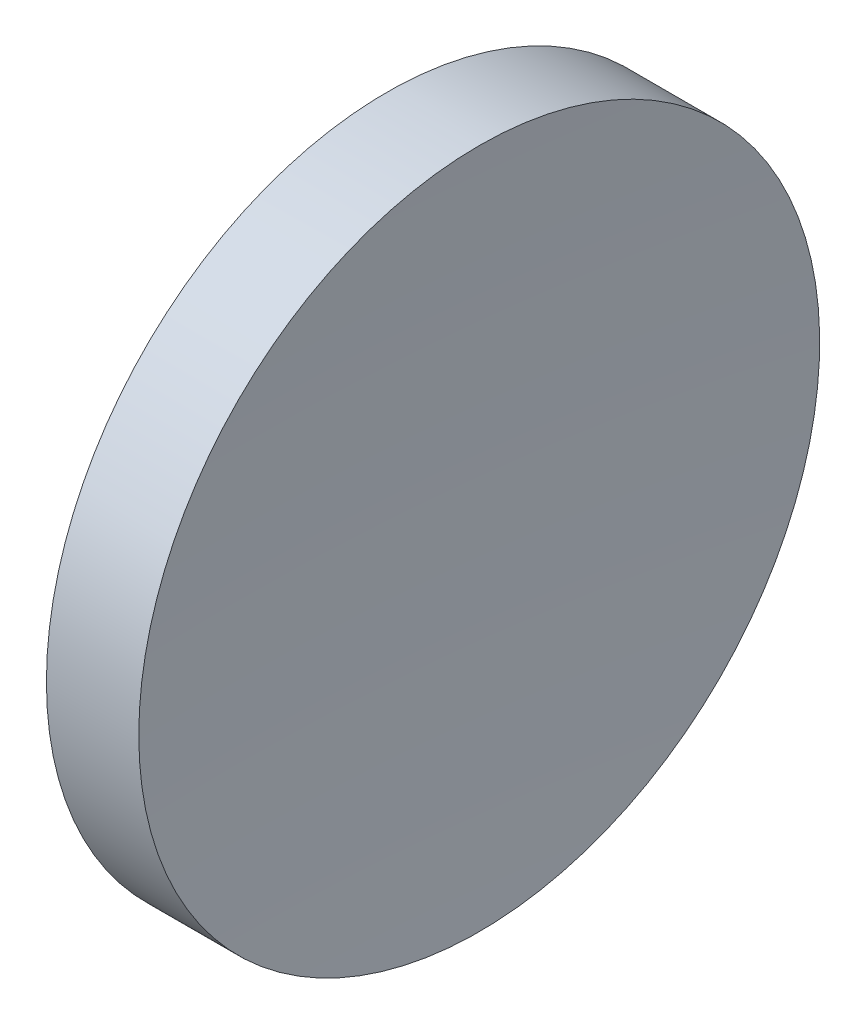
from build123d import *


with BuildPart() as part:
    # 草图1 → 旋转1 (revolve)
    with BuildSketch(Plane.XY):
        with BuildLine():
            Line((230.199611905, 138.756042247), (230.199611905, 176.256042247))
            Line((230.199611905, 176.256042247), (240.372630706, 176.256042247))
            ThreePointArc((240.372630706, 176.256042247), (239.49293617, 157.515213203), (239.199609057, 138.756042247))
            Line((239.199609057, 138.756042247), (230.199611905, 138.756042247))
        make_face()
    revolve(axis=Axis((217.970286004, 138.756042247, 0), (1, 0, 0)))


solid = part.part
